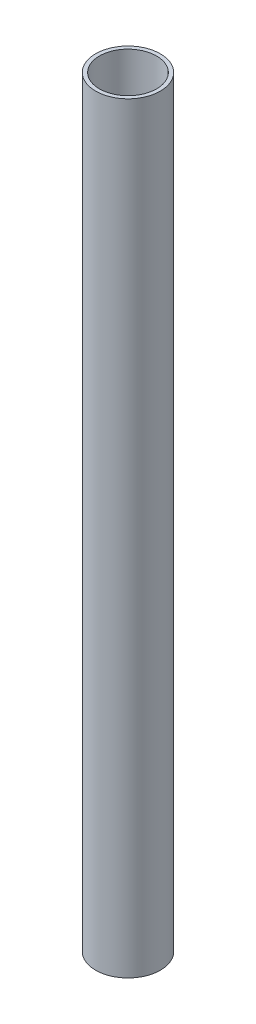
from build123d import *

# Parameters (mm, degrees)
SKETCH_1_R      = 25.5
SKETCH_1_R_2    = 22.5
EXTRUDE_1_DEPTH = 600


with BuildPart() as part:
    # Эскиз1 → Вытянуть-Тонкостенный1 (new body)
    with BuildSketch(Plane(origin=(0, 0, 0), x_dir=(1, 0, 0), z_dir=(0, 1, 0))):
        Circle(SKETCH_1_R)
        Circle(SKETCH_1_R_2, mode=Mode.SUBTRACT)
    extrude(amount=EXTRUDE_1_DEPTH)


solid = part.part
